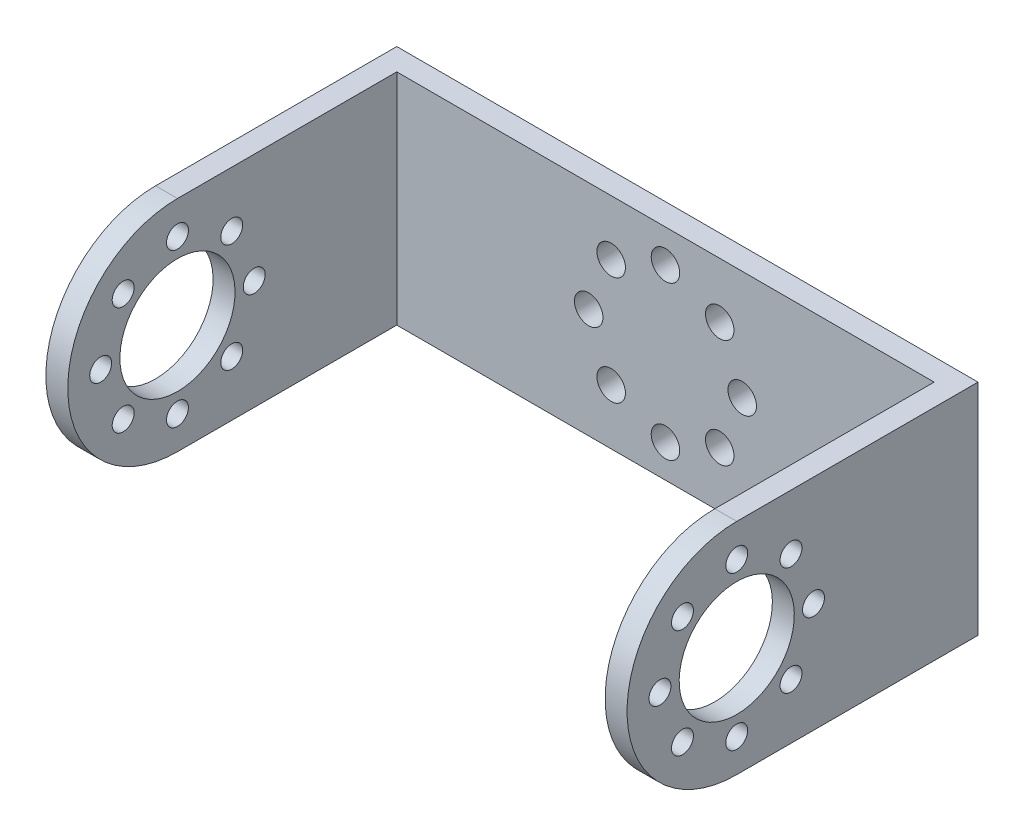
from build123d import *

# Parameters (mm, degrees)
SKETCH_1_W          = 53
SKETCH_1_H          = 20
EXTRUDE_1_DEPTH     = 2
SKETCH_2_W          = 2
SKETCH_2_H          = 20
EXTRUDE_2_DEPTH     = 30
CUT_EXTRUDE_START   = -30
CUT_EXTRUDE_1_DEPTH = 82
SKETCH_4_R          = 1
SKETCH_4_R_2        = 5.25
CUT_EXTRUDE_2_DEPTH = 2
SKETCH_5_R          = 1.3
CUT_EXTRUDE_3_DEPTH = 33


with BuildPart() as part:
    # 草圖1 → 填料-伸長1 (new body)
    with BuildSketch(Plane.XY):
        Rectangle(SKETCH_1_W, SKETCH_1_H)
    extrude(amount=EXTRUDE_1_DEPTH)

    # 草圖2 → 填料-伸長2 (add)
    with BuildSketch(Plane.XY.offset(2)):
        with Locations((-25.5, 0)):
            Rectangle(SKETCH_2_W, SKETCH_2_H)
    extrude_2 = extrude(amount=EXTRUDE_2_DEPTH)

    # 草圖3 → 除料-伸長1 (cut)
    with BuildSketch(Plane(origin=(-24.5, 0, 0), x_dir=(0, 0, -1), z_dir=(1, 0, 0)).offset(CUT_EXTRUDE_START)):
        with BuildLine():
            Line((-32, 10), (-32, 0))
            ThreePointArc((-32, 0), (-29.071067812, 7.071067812), (-22, 10))
            Line((-22, 10), (-32, 10))
        make_face()
        with BuildLine():
            Line((-32, -10), (-22, -10))
            ThreePointArc((-22, -10), (-29.071067812, -7.071067812), (-32, 0))
            Line((-32, 0), (-32, -10))
        make_face()
    cut_extrude_1 = extrude(amount=CUT_EXTRUDE_1_DEPTH, mode=Mode.SUBTRACT)

    # 草圖4 → 除料-伸長2 (cut)
    with BuildSketch(Plane.ZY.offset(26.5)):
        with Locations((29, 0)):
            Circle(SKETCH_4_R)
        with Locations((26.949747468, -4.949747468)):
            Circle(SKETCH_4_R)
        with Locations((22, -7)):
            Circle(SKETCH_4_R)
        with Locations((17.050252532, -4.949747468)):
            Circle(SKETCH_4_R)
        with Locations((15, 0)):
            Circle(SKETCH_4_R)
        with Locations((17.050252532, 4.949747468)):
            Circle(SKETCH_4_R)
        with Locations((22, 7)):
            Circle(SKETCH_4_R)
        with Locations((26.949747468, 4.949747468)):
            Circle(SKETCH_4_R)
        with Locations((22, 0)):
            Circle(SKETCH_4_R_2)
    cut_extrude_2 = extrude(amount=-CUT_EXTRUDE_2_DEPTH, mode=Mode.SUBTRACT)

    # 鏡射1: 填料-伸長2, 除料-伸長1, 除料-伸長2 across plane
    add(extrude_2.mirror(Plane(origin=(0, 0, 0), x_dir=(0, 0, 1), z_dir=(1, 0, 0))))
    add(cut_extrude_1.mirror(Plane(origin=(0, 0, 0), x_dir=(0, 0, 1), z_dir=(1, 0, 0))), mode=Mode.SUBTRACT)
    add(cut_extrude_2.mirror(Plane(origin=(0, 0, 0), x_dir=(0, 0, 1), z_dir=(1, 0, 0))), mode=Mode.SUBTRACT)

    # 草圖5 → 除料-伸長3 (cut, through all)
    with BuildSketch(Plane(origin=(0, 0, 0), x_dir=(-1, 0, 0), z_dir=(0, 0, -1))):
        with Locations((-7, 0)):
            Circle(SKETCH_5_R)
        with Locations((-4.949747468, 4.949747468)):
            Circle(SKETCH_5_R)
        with Locations((0, 7)):
            Circle(SKETCH_5_R)
        with Locations((4.949747468, 4.949747468)):
            Circle(SKETCH_5_R)
        with Locations((7, 0)):
            Circle(SKETCH_5_R)
        with Locations((4.949747468, -4.949747468)):
            Circle(SKETCH_5_R)
        with Locations((0, -7)):
            Circle(SKETCH_5_R)
        with Locations((-4.949747468, -4.949747468)):
            Circle(SKETCH_5_R)
    extrude(amount=-CUT_EXTRUDE_3_DEPTH, mode=Mode.SUBTRACT)


solid = part.part
